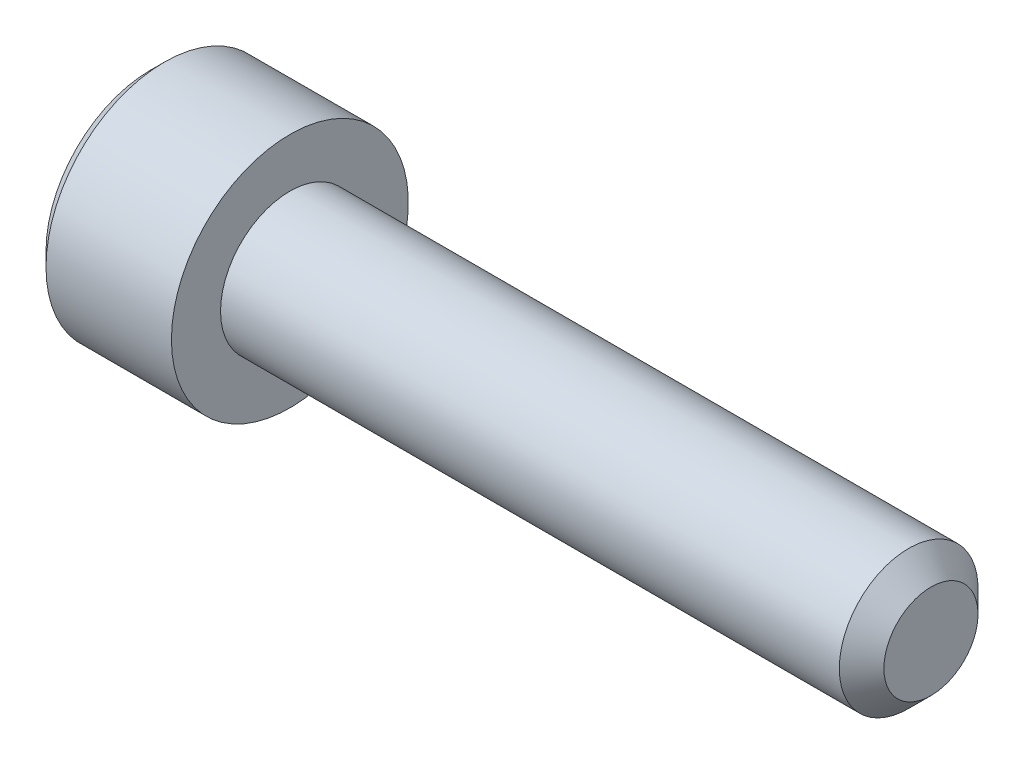
from build123d import *

# Parameters (mm, degrees)
CHAMFER1_SIZE      = 0.8
CHAMFER2_SIZE      = 0.5
CUT_EXTRUDE1_DEPTH = 2.5
CHAMFER3_SIZE      = 0.4


with BuildPart() as part:
    # Sketch1 → Revolve1 (revolve)
    with BuildSketch(Plane.XY):
        Polygon((0, 0), (0, 4.25), (5, 4.25), (5, 2.488), (28, 2.488), (28, 0), align=None)
    revolve(axis=Axis((-88.705490849, 0, 0), (1, 0, 0)))

    # Chamfer1
    chamfer1_edges = [part.edges().sort_by_distance(p)[0] for p in [
        (28, -2.488, 0),
    ]]
    chamfer(chamfer1_edges, length=CHAMFER1_SIZE)

    # Chamfer2
    chamfer2_edges = [part.edges().sort_by_distance(p)[0] for p in [
        (0, -4.25, 0),
    ]]
    chamfer(chamfer2_edges, length=CHAMFER2_SIZE)

    # Sketch3 → Cut-Extrude1 (cut)
    with BuildSketch(Plane(origin=(0, 0, 0), x_dir=(0, 0, -1), z_dir=(1, 0, 0))):
        Polygon((-2.309401077, 0), (-1.154700538, -2), (1.154700538, -2), (2.309401077, 0), (1.154700538, 2), (-1.154700538, 2), align=None)
    extrude(amount=CUT_EXTRUDE1_DEPTH, mode=Mode.SUBTRACT)

    # Chamfer3
    chamfer3_edges = [part.edges().sort_by_distance(p)[0] for p in [
        (0, 1, 1.732050808),
        (0, -1, 1.732050808),
        (0, -2, 0),
        (0, -1, -1.732050808),
        (0, 1, -1.732050808),
        (0, 2, 0),
    ]]
    chamfer(chamfer3_edges, length=CHAMFER3_SIZE)


solid = part.part
